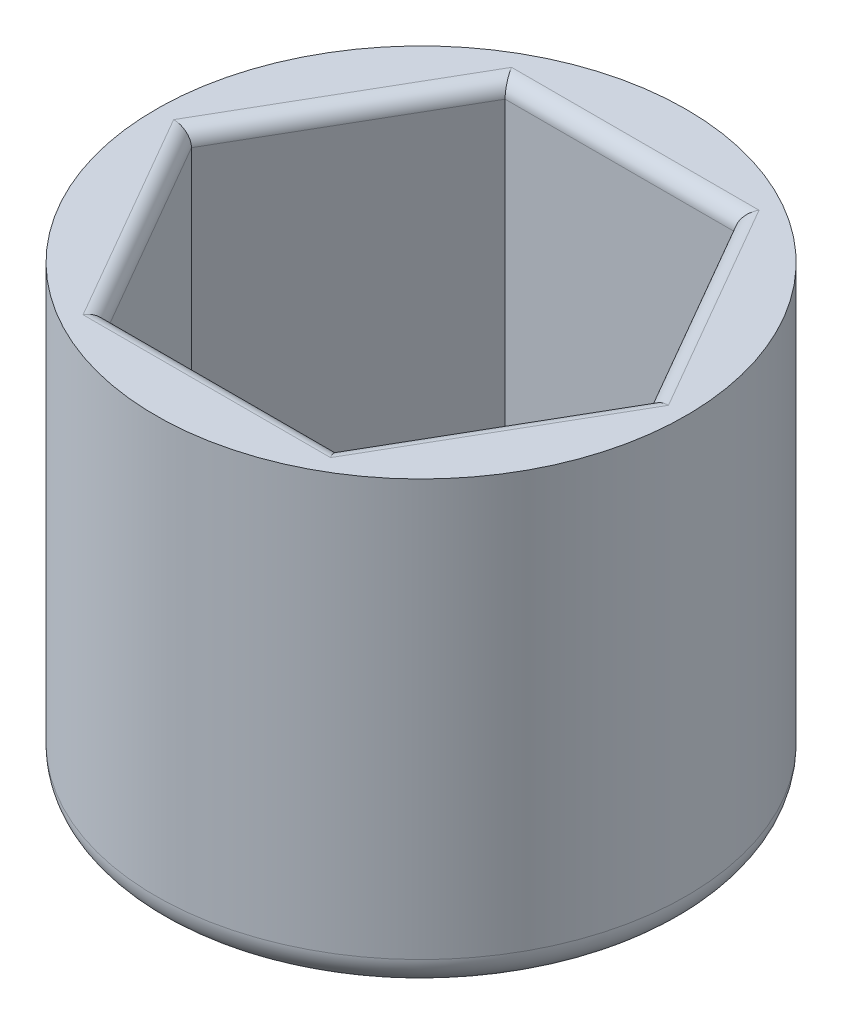
from build123d import *

# Parameters (mm, degrees)
SALIENTE_EXTRUIR1_DEPTH = 12
SALIENTE_EXTRUIR2_DEPTH = 2.5
REDONDEO2_R             = 0.5
SALIENTE_EXTRUIR4_DEPTH = 14.5
REDONDEO5_R             = 1


with BuildPart() as part:
    # Croquis1 → Saliente-Extruir1 (new body)
    with BuildSketch(Plane(origin=(0, 0, 0), x_dir=(1, 0, 0), z_dir=(0, 1, 0))):
        Polygon((8.602519010925427, 1.1e-16), (4.301259505462714, 7.45), (-4.30125950546271, 7.450000000000001), (-8.602519010925425, 1.1e-16), (-4.301259505462709, -7.450000000000002), (4.301259505462713, -7.450000000000001), align=None)
        Polygon((-3.723909236273085, 6.45), (-7.447818472546173, 8.7e-16), (-3.723909236273083, -6.450000000000002), (3.723909236273086, -6.450000000000001), (7.4478184725461745, 0), (3.7239092362730872, 6.45), align=None, mode=Mode.SUBTRACT)
    extrude(amount=SALIENTE_EXTRUIR1_DEPTH)

    # Croquis2 → Saliente-Extruir2 (add)
    with BuildSketch(Plane.XZ):
        Polygon((8.602519010925427, -1.1e-16), (4.301259505462713, 7.450000000000001), (-4.301259505462709, 7.450000000000002), (-8.602519010925425, -1.1e-16), (-4.30125950546271, -7.450000000000001), (4.301259505462714, -7.45), align=None)
    extrude(amount=SALIENTE_EXTRUIR2_DEPTH)

    # Redondeo2
    redondeo2_edges = [part.edges().sort_by_distance(p)[0] for p in [
        (8.9e-16, 12, -6.45),
        (-5.585863854409629, 12, -3.2250000000000005),
        (-5.585863854409627, 12, 3.2250000000000005),
        (1.78e-15, 12, 6.450000000000001),
        (5.585863854409631, 12, 3.2250000000000005),
        (5.585863854409631, 12, -3.225),
    ]]
    fillet(redondeo2_edges, radius=REDONDEO2_R)

    # Croquis3 → Saliente-Extruir4 (add)
    with BuildSketch(Plane.XZ.offset(2.5)):
        with BuildLine():
            Line((4.301259505462713, 7.450000000000002), (8.602519010925427, -1.1e-16))
            ThreePointArc((8.602519010925423, 0), (7.45, 4.301259505462711), (4.3012595054627125, 7.449999999999999))
        make_face()
        with BuildLine():
            ThreePointArc((4.3012595054627125, 7.449999999999999), (5.3e-16, 8.602519010925423), (-4.30125950546271, 7.45))
            Line((-4.30125950546271, 7.450000000000002), (4.301259505462713, 7.450000000000001))
        make_face()
        with BuildLine():
            ThreePointArc((-4.30125950546271, 7.45), (-7.449999999999998, 4.301259505462714), (-8.602519010925423, 1.05e-15))
            Line((-8.602519010925425, 0), (-4.301259505462709, 7.450000000000002))
        make_face()
        with BuildLine():
            ThreePointArc((-8.602519010925423, 1.05e-15), (-7.449999999999999, -4.3012595054627125), (-4.301259505462708, -7.450000000000001))
            Line((-4.30125950546271, -7.450000000000001), (-8.602519010925425, -1.1e-16))
        make_face()
        with BuildLine():
            Line((4.301259505462713, -7.45), (-4.30125950546271, -7.450000000000001))
            ThreePointArc((-4.301259505462708, -7.450000000000001), (-1.58e-15, -8.602519010925423), (4.3012595054627125, -7.449999999999999))
        make_face()
        with BuildLine():
            Line((8.602519010925427, 0), (4.301259505462714, -7.45))
            ThreePointArc((4.3012595054627125, -7.449999999999999), (7.450000000000001, -4.301259505462709), (8.602519010925423, -2.11e-15))
        make_face()
    extrude(amount=-SALIENTE_EXTRUIR4_DEPTH)

    # Redondeo5
    redondeo5_edges = [part.edges().sort_by_distance(p)[0] for p in [
        (8.602519010925413, -2.5, 5.94e-15),
    ]]
    fillet(redondeo5_edges, radius=REDONDEO5_R)


solid = part.part
